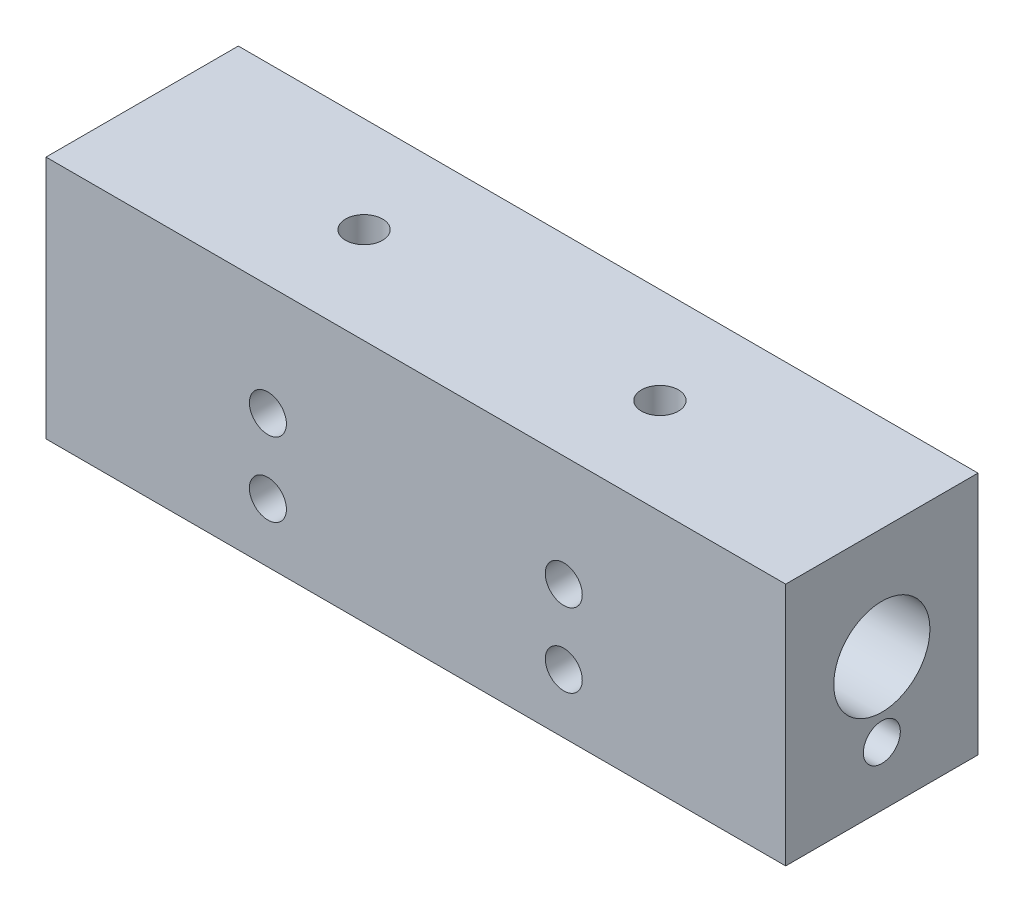
from build123d import *

# Parameters (mm, degrees)
SKETCH1_W             = 50
SKETCH1_H             = 16.5
BOSS_EXTRUDE1_DEPTH   = 6.5
LPATTERN1_COUNT       = 2
LPATTERN1_PITCH       = 20
SKETCH4_R             = 3.25
CUT_EXTRUDE1_DEPTH    = 51
M3X0_5_TAPPED_HOLE2_D = 2.5
LPATTERN2_COUNT       = 2
LPATTERN2_PITCH       = 20
LPATTERN2_COUNT_DIR2  = 2
LPATTERN2_PITCH_DIR2  = 5
SKETCH9_W             = 17
SKETCH9_H             = 1
BOSS_EXTRUDE2_DEPTH   = 2


with BuildPart() as part:
    # Sketch1 → Boss-Extrude1 (new body, symmetric)
    with BuildSketch(Plane.XY):
        Rectangle(SKETCH1_W, SKETCH1_H)
    extrude(amount=BOSS_EXTRUDE1_DEPTH, both=True)

    # Sketch2 → M3x0.5 Tapped Hole1 (revolve, cut)
    with BuildSketch(Plane(origin=(10, 8.25, 0), x_dir=(0, 0, 1), z_dir=(1, 0, 0))):
        Polygon((0, 0), (0, 7.5), (1.25, 6.748924226), (1.25, 0), align=None)
    m3x0_5_tapped_hole1 = revolve(axis=Axis((10, 14.6, 0), (0, -1, 0)), mode=Mode.SUBTRACT)

    # LPattern1: M3x0.5 Tapped Hole1 ×2
    with Locations(*[(-i * LPATTERN1_PITCH, 0, 0) for i in range(1, LPATTERN1_COUNT)]):
        add(m3x0_5_tapped_hole1, mode=Mode.SUBTRACT)

    # Sketch4 → Cut-Extrude1 (cut, through all)
    with BuildSketch(Plane(origin=(25, 0, 0), x_dir=(0, 0, -1), z_dir=(1, 0, 0))):
        with Locations((0, 0.75)):
            Circle(SKETCH4_R)
    extrude(amount=-CUT_EXTRUDE1_DEPTH, mode=Mode.SUBTRACT)

    # M3x0.5 Tapped Hole2 (through all)
    with Locations(Plane(origin=(25, 0, 0), x_dir=(0, 0, -1), z_dir=(1, 0, 0))):
        with Locations((0, -4.25)):
            Hole(M3X0_5_TAPPED_HOLE2_D / 2)

    # Sketch7 → M3x0.5 Tapped Hole3 (revolve, cut)
    with BuildSketch(Plane(origin=(-10, 0.75, 6.5), x_dir=(0, -1, 0), z_dir=(1, 0, 0))):
        Polygon((0, 0), (0, 7.5), (1.25, 6.748924226), (1.25, 0), align=None)
    m3x0_5_tapped_hole3 = revolve(axis=Axis((-10, 0.75, 12.85), (0, 0, -1)), mode=Mode.SUBTRACT)

    # LPattern2: M3x0.5 Tapped Hole3 2 × 2
    with Locations(*[(i * LPATTERN2_PITCH, -j * LPATTERN2_PITCH_DIR2, 0) for i in range(LPATTERN2_COUNT) for j in range(LPATTERN2_COUNT_DIR2) if (i, j) != (0, 0)]):
        add(m3x0_5_tapped_hole3, mode=Mode.SUBTRACT)

    # Sketch9 → Boss-Extrude2 (add)
    with BuildSketch(Plane.XZ.offset(8.25)):
        with Locations((0, 4)):
            Rectangle(SKETCH9_W, SKETCH9_H)
    extrude(amount=BOSS_EXTRUDE2_DEPTH)


solid = part.part
